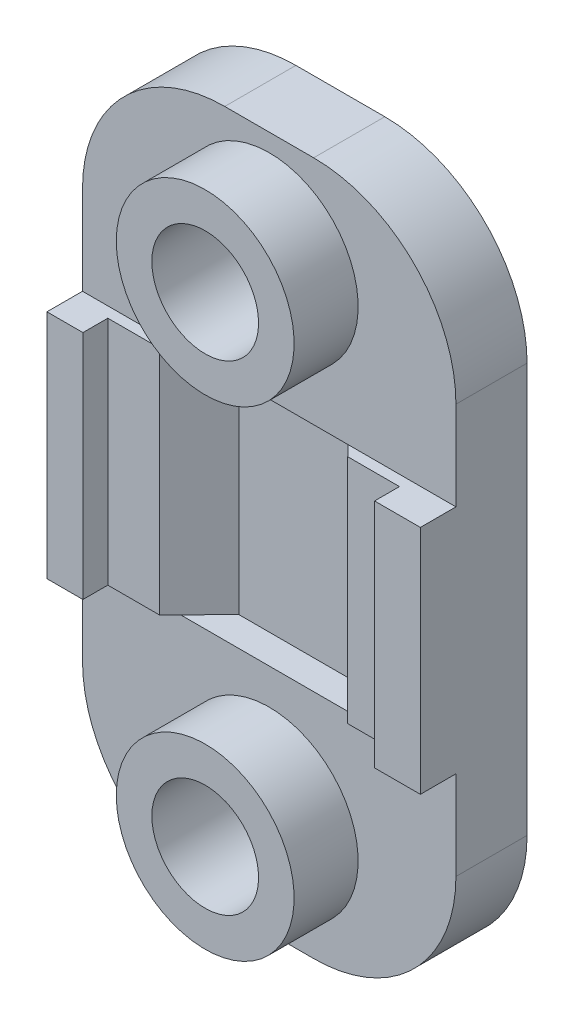
from build123d import *

# Parameters (mm, degrees)
DODANIE_WYCI_GNI_CIE4_DEPTH = 13
SZKIC4_W                    = 21
SZKIC4_H                    = 13
DODANIE_WYCI_GNI_CIE5_DEPTH = 2
SZKIC5_W                    = 21
SZKIC5_H                    = 13
SZKIC5_R                    = 3
DODANIE_WYCI_GNI_CIE6_DEPTH = 4
DODANIE_WYCI_GNI_CIE7_START = -4
SZKIC5_4_R                  = 3
DODANIE_WYCI_GNI_CIE7_DEPTH = 3.6
ZAOKR_GLENIE3_R             = 8


with BuildPart() as part:
    # Szkic3 → Dodanie-wyci_gni_cie4 (new body)
    with BuildSketch(Plane(origin=(0, 0, 0), x_dir=(1, 0, 0), z_dir=(0, 1, 0))):
        Polygon((7.923824764, -2), (7.923824764, -0.6), (5.016097838, -0.6), (2.807764504, 1.65), (-3.360114975, 1.65), (-5.568448309, -0.6), (-8.476175236, -0.6), (-8.476175236, -2), (-10.5, -2), (-10.5, 2), (10.5, 2), (10.5, -2), align=None)
    extrude(amount=DODANIE_WYCI_GNI_CIE4_DEPTH)

    # Szkic4 → Dodanie-wyci_gni_cie5 (add)
    with BuildSketch(Plane(origin=(0, 0, -2), x_dir=(-1, 0, 0), z_dir=(0, 0, -1))):
        with Locations((0, 6.5)):
            Rectangle(SZKIC4_W, SZKIC4_H)
    extrude(amount=DODANIE_WYCI_GNI_CIE5_DEPTH)

    # Szkic5 → Dodanie-wyci_gni_cie6 (add)
    with BuildSketch(Plane(origin=(0, 0, -4), x_dir=(-1, 0, 0), z_dir=(0, 0, -1))):
        with Locations((0, 19.5)):
            Rectangle(SZKIC5_W, SZKIC5_H)
        with Locations((0, 20)):
            Circle(SZKIC5_R, mode=Mode.SUBTRACT)
        with Locations((0, -6.5)):
            Rectangle(SZKIC5_W, SZKIC5_H)
        with Locations((0, -7)):
            Circle(SZKIC5_R, mode=Mode.SUBTRACT)
    extrude(amount=-DODANIE_WYCI_GNI_CIE6_DEPTH)

    # Szkic5_4 → Dodanie-wyci_gni_cie7 (add)
    with BuildSketch(Plane(origin=(0, 0, -4), x_dir=(-1, 0, 0), z_dir=(0, 0, -1)).offset(DODANIE_WYCI_GNI_CIE7_START)):
        with BuildLine():
            Line((3, 16), (-3, 16))
            ThreePointArc((-3, 16), (0, 15), (3, 16))
        make_face()
        with BuildLine():
            ThreePointArc((5, 20), (-2.236067977, 24.472135955), (-3, 16))
            Line((-3, 16), (3, 16))
            ThreePointArc((3, 16), (4.472135955, 17.763932023), (5, 20))
        make_face()
        with Locations((0, 20)):
            Circle(SZKIC5_4_R, mode=Mode.SUBTRACT)
        with BuildLine():
            Line((-3, -3), (3, -3))
            ThreePointArc((3, -3), (0, -2), (-3, -3))
        make_face()
        with BuildLine():
            ThreePointArc((5, -7), (4.472135955, -4.763932023), (3, -3))
            Line((3, -3), (-3, -3))
            ThreePointArc((-3, -3), (-2.236067977, -11.472135955), (5, -7))
        make_face()
        with Locations((0, -7)):
            Circle(SZKIC5_4_R, mode=Mode.SUBTRACT)
    extrude(amount=-DODANIE_WYCI_GNI_CIE7_DEPTH)

    # Zaokr_glenie3
    zaokr_glenie3_edges = [part.edges().sort_by_distance(p)[0] for p in [
        (-10.5, -13, -2),
        (10.5, -13, -2),
        (10.5, 26, -2),
        (-10.5, 26, -2),
    ]]
    fillet(zaokr_glenie3_edges, radius=ZAOKR_GLENIE3_R)


solid = part.part
